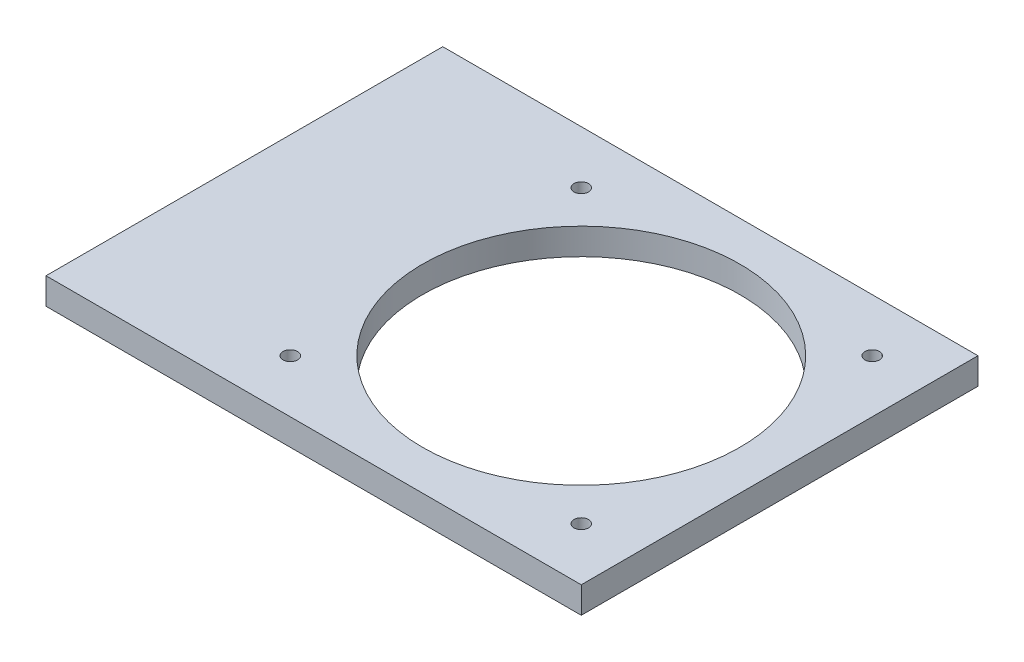
from build123d import *

# Parameters (mm, degrees)
SKETCH5_W           = 128.500510093
SKETCH5_H           = 6.35
BOSS_EXTRUDE1_DEPTH = 95.25
SKETCH6_R           = 38.1
SKETCH6_R_2         = 1.75
CUT_EXTRUDE3_DEPTH  = 7.35


with BuildPart() as part:
    # Sketch5 → Boss-Extrude1 (new body)
    with BuildSketch(Plane.XY):
        with Locations((91.472352703, 307.975)):
            Rectangle(SKETCH5_W, SKETCH5_H)
    extrude(amount=BOSS_EXTRUDE1_DEPTH)

    # Sketch6 → Cut-Extrude3 (cut, through all)
    with BuildSketch(Plane(origin=(0, 311.15, 0), x_dir=(1, 0, 0), z_dir=(0, 1, 0))):
        with Locations((108.097607749, -47.625)):
            Circle(SKETCH6_R)
        with Locations((73.172607749, -12.7)):
            Circle(SKETCH6_R_2)
        with Locations((73.172607749, -82.55)):
            Circle(SKETCH6_R_2)
        with Locations((143.022607749, -82.55)):
            Circle(SKETCH6_R_2)
        with Locations((143.022607749, -12.7)):
            Circle(SKETCH6_R_2)
    extrude(amount=-CUT_EXTRUDE3_DEPTH, mode=Mode.SUBTRACT)


solid = part.part
